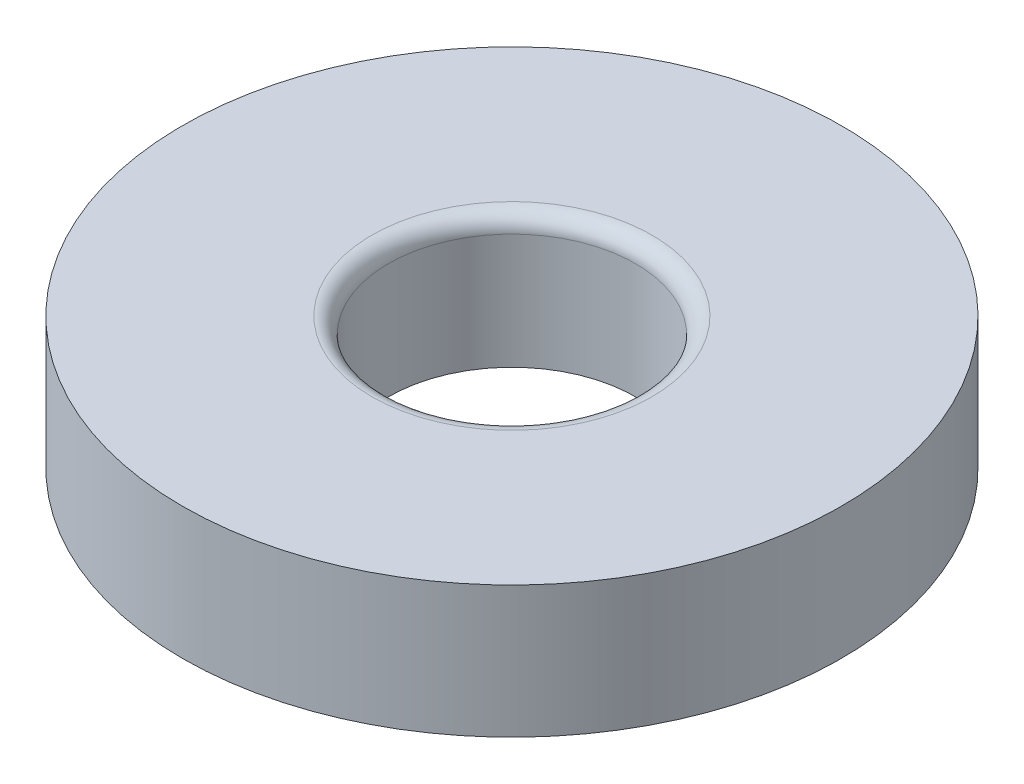
from build123d import *

# Parameters (mm, degrees)
SKETCH1_R           = 20
BOSS_EXTRUDE1_DEPTH = 8
SKETCH2_R           = 7.5
CUT_EXTRUDE1_DEPTH  = 9
FILLET1_R           = 1


with BuildPart() as part:
    # Sketch1 → Boss-Extrude1 (new body)
    with BuildSketch(Plane(origin=(0, 0, 0), x_dir=(1, 0, 0), z_dir=(0, 1, 0))):
        Circle(SKETCH1_R)
    extrude(amount=BOSS_EXTRUDE1_DEPTH)

    # Sketch2 → Cut-Extrude1 (cut, through all)
    with BuildSketch(Plane(origin=(0, 8, 0), x_dir=(1, 0, 0), z_dir=(0, 1, 0))):
        Circle(SKETCH2_R)
    extrude(amount=-CUT_EXTRUDE1_DEPTH, mode=Mode.SUBTRACT)

    # Fillet1
    fillet1_edges = [part.edges().sort_by_distance(p)[0] for p in [
        (-7.5, 8, 0),
    ]]
    fillet(fillet1_edges, radius=FILLET1_R)


solid = part.part
